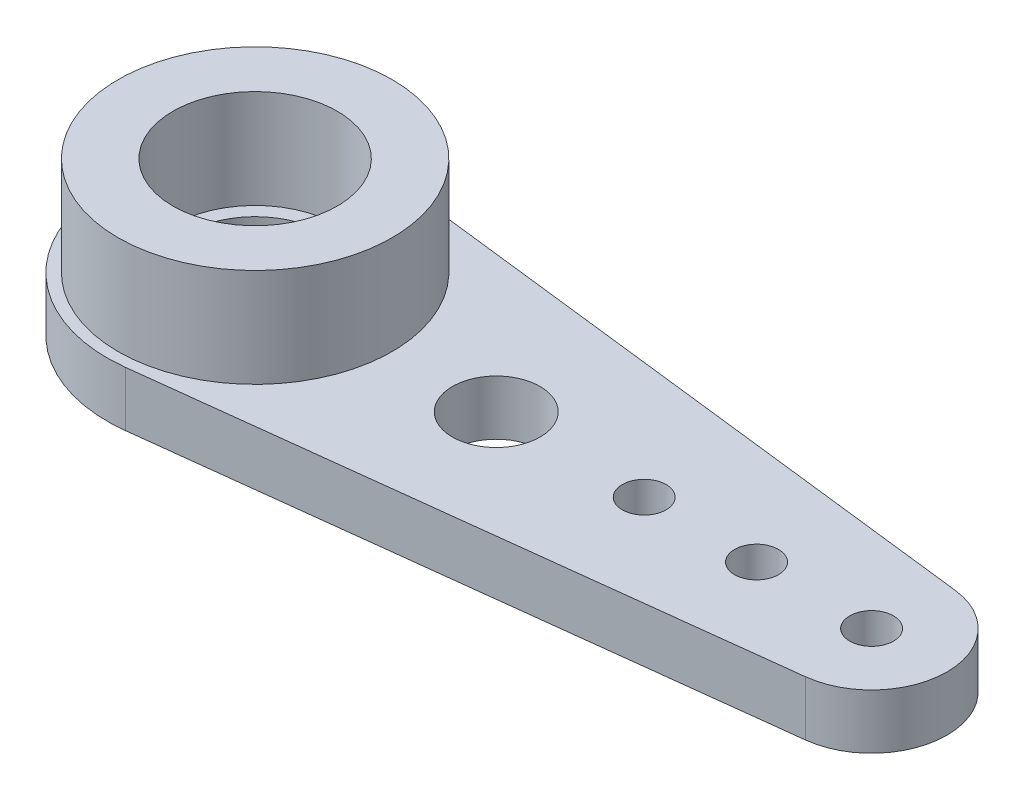
from build123d import *

# Parameters (mm, degrees)
SKETCH_1_R        = 2.5
SKETCH_1_R_2      = 1.6
SKETCH_1_R_3      = 0.8
EXTRUDE_1_DEPTH   = 2
SKETCH_4_R        = 5
SKETCH_4_R_2      = 3
EXTRUDE_1_2_DEPTH = 3.6


with BuildPart() as part:
    # 草圖1 → Extrude 1 (new body)
    with BuildSketch(Plane(origin=(0, 0, 0), x_dir=(1, 0, 0), z_dir=(0, 1, 0))):
        with BuildLine():
            Line((0.636, 5.362415873), (22.823888889, 2.730859936))
            ThreePointArc((22.823888889, 2.730859936), (25.25, 0), (22.823888889, -2.730859936))
            Line((22.823888889, -2.730859936), (0.636, -5.362415873))
            ThreePointArc((0.636, -5.362415873), (-5.4, 0), (0.636, 5.362415873))
        make_face()
        Circle(SKETCH_1_R, mode=Mode.SUBTRACT)
        with Locations((8.8, 0)):
            Circle(SKETCH_1_R_2, mode=Mode.SUBTRACT)
        with Locations((14.2, 0)):
            Circle(SKETCH_1_R_3, mode=Mode.SUBTRACT)
        with Locations((18.3, 0)):
            Circle(SKETCH_1_R_3, mode=Mode.SUBTRACT)
        with Locations((22.5, 0)):
            Circle(SKETCH_1_R_3, mode=Mode.SUBTRACT)
    extrude(amount=EXTRUDE_1_DEPTH)

    # 草圖4 → Extrude 1 2 (add)
    with BuildSketch(Plane(origin=(0, 2, 0), x_dir=(1, 0, 0), z_dir=(0, 1, 0))):
        Circle(SKETCH_4_R)
        Circle(SKETCH_4_R_2, mode=Mode.SUBTRACT)
    extrude(amount=EXTRUDE_1_2_DEPTH)


solid = part.part
